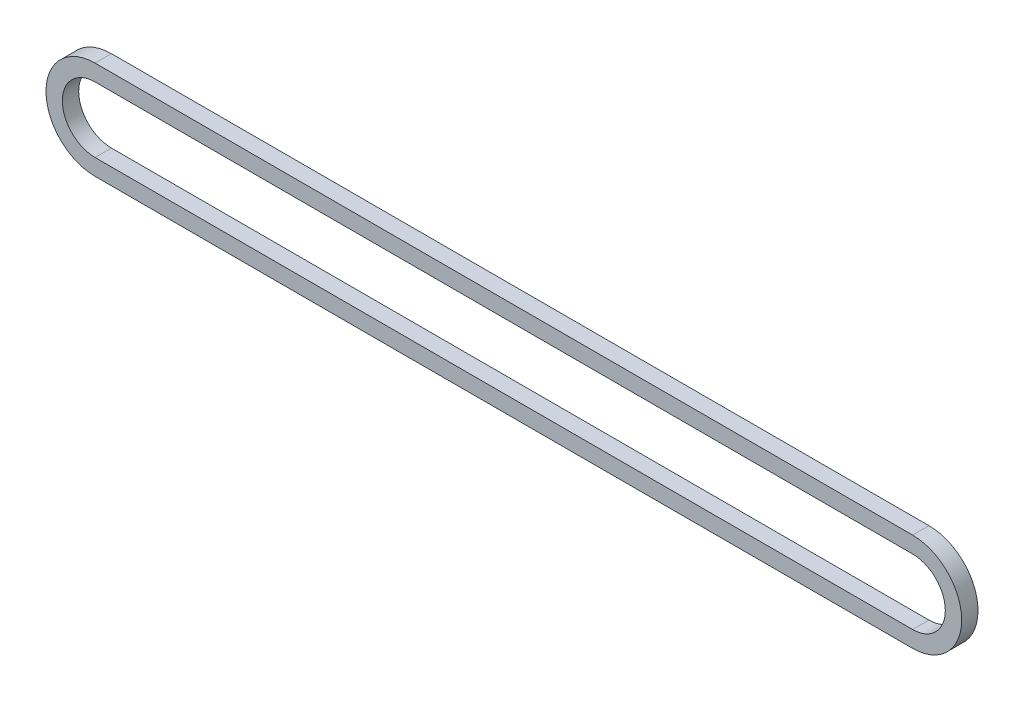
from build123d import *

# Parameters (mm, degrees)
EXTRUDE_1_DEPTH = 2


with BuildPart() as part:
    # 草图1 → 凸台-拉伸1 (new body)
    with BuildSketch(Plane.XY):
        with BuildLine():
            Line((-52.314570525, -6), (47.685429475, -6))
            ThreePointArc((47.685429475, -6), (53.685429475, 0), (47.685429475, 6))
            Line((47.685429475, 6), (-52.314570525, 6))
            ThreePointArc((-52.314570525, 6), (-58.314570525, 0), (-52.314570525, -6))
        make_face()
        with BuildLine():
            Line((-52.314570525, -4), (47.685429475, -4))
            ThreePointArc((47.685429475, -4), (51.685429475, 0), (47.685429475, 4))
            Line((47.685429475, 4), (-52.314570525, 4))
            ThreePointArc((-52.314570525, 4), (-56.314570525, 0), (-52.314570525, -4))
        make_face(mode=Mode.SUBTRACT)
    extrude(amount=EXTRUDE_1_DEPTH)


solid = part.part
